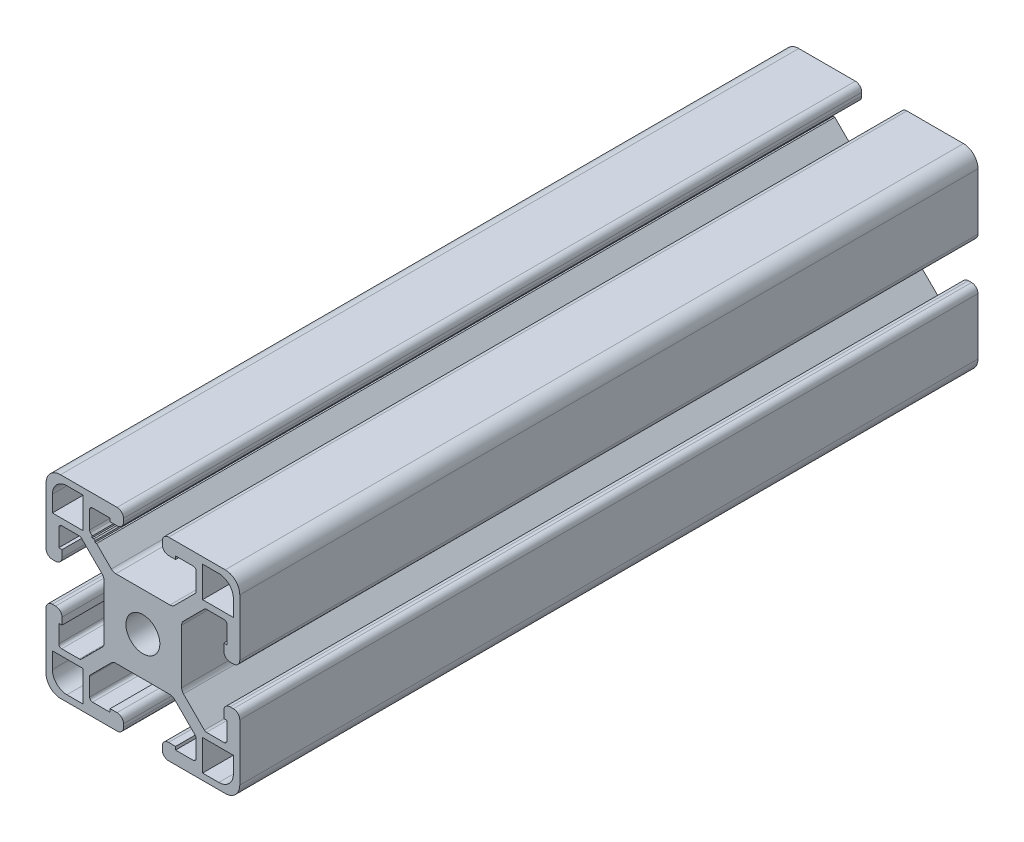
from build123d import *

# Parameters (mm, degrees)
BOSS_EXTRUDE1_DEPTH     = 76.2
CUT_EXTRUDE1_DEPTH      = 77.2
CUT_EXTRUDE1_DEPTH_BACK = 77.2


with BuildPart() as part:
    # Sketch4 → Boss-Extrude1 (new body, symmetric)
    with BuildSketch(Plane.XY):
        with BuildLine():
            Line((20, -17), (20, -5.32))
            ThreePointArc((20, -5.32), (19.613380951, -4.386619049), (18.68, -4))
            Line((18.68, -4), (18.02, -4))
            ThreePointArc((18.02, -4), (17.086619049, -4.386619049), (16.7, -5.32))
            Line((16.7, -5.32), (16.7, -6.75))
            Line((16.7, -6.75), (17.36, -6.75))
            Line((17.36, -6.75), (17.36, -10.4))
            ThreePointArc((17.36, -10.4), (17.184264069, -10.824264069), (16.76, -11))
            Line((16.76, -11), (13.11529004, -11))
            ThreePointArc((13.11529004, -11), (12.88567998, -10.95432772), (12.691025971, -10.824264069))
            Line((12.691025971, -10.824264069), (8.386619049, -6.519857147))
            ThreePointArc((8.386619049, -6.519857147), (8.100479017, -6.091618326), (8, -5.586476195))
            Line((8, -5.586476195), (8, 0))
            Line((8, 0), (3.5, 0))
            ThreePointArc((3.5, 0), (2.474873734, -2.474873734), (0, -3.5))
            Line((0, -3.5), (0, -8))
            Line((0, -8), (5.586476195, -8))
            ThreePointArc((5.586476195, -8), (6.091618326, -8.100479017), (6.519857147, -8.386619049))
            Line((6.519857147, -8.386619049), (10.824264069, -12.691025971))
            ThreePointArc((10.824264069, -12.691025971), (10.95432772, -12.88567998), (11, -13.11529004))
            Line((11, -13.11529004), (11, -16.76))
            ThreePointArc((11, -16.76), (10.824264069, -17.184264069), (10.4, -17.36))
            Line((10.4, -17.36), (6.75, -17.36))
            Line((6.75, -17.36), (6.75, -16.7))
            Line((6.75, -16.7), (5.32, -16.7))
            ThreePointArc((5.32, -16.7), (4.386619049, -17.086619049), (4, -18.02))
            Line((4, -18.02), (4, -18.68))
            ThreePointArc((4, -18.68), (4.386619049, -19.613380951), (5.32, -20))
            Line((5.32, -20), (17, -20))
            ThreePointArc((17, -20), (19.121320344, -19.121320344), (20, -17))
        make_face()
        with BuildLine():
            Line((15.68, -18.68), (12.32, -18.68))
            Line((12.32, -18.68), (12.32, -12.32))
            Line((12.32, -12.32), (18.68, -12.32))
            Line((18.68, -12.32), (18.68, -15.68))
            ThreePointArc((18.68, -15.68), (17.801320344, -17.801320344), (15.68, -18.68))
        make_face(mode=Mode.SUBTRACT)
    extrude(amount=BOSS_EXTRUDE1_DEPTH, both=True)

    # Mirror1: part across plane


with BuildPart() as part_1:
    add(part.part)
    add(part.part.mirror(Plane(origin=(0, 0, 0), x_dir=(0, 0, 1), z_dir=(1, 0, 0))))

    # Mirror2: part across plane


with BuildPart() as part_2:
    add(part_1.part)
    add(part_1.part.mirror(Plane.ZX))

    # Sketch5 → Cut-Extrude1 (cut, two sides)
    with BuildSketch(Plane.XY) as cut_extrude1_sk:
        Polygon((-10.453238098, 12.32), (-10.453238098, 11.99), (-10.123238098, 11.99), (-9.88989286, 11.756654762), (-9.88989286, 11.426654762), (-9.55989286, 11.426654762), (-9.55989286, 12.32), align=None)
    extrude(amount=CUT_EXTRUDE1_DEPTH, mode=Mode.SUBTRACT)
    extrude(cut_extrude1_sk.sketch, amount=-CUT_EXTRUDE1_DEPTH_BACK, mode=Mode.SUBTRACT)


solid = part_2.part
